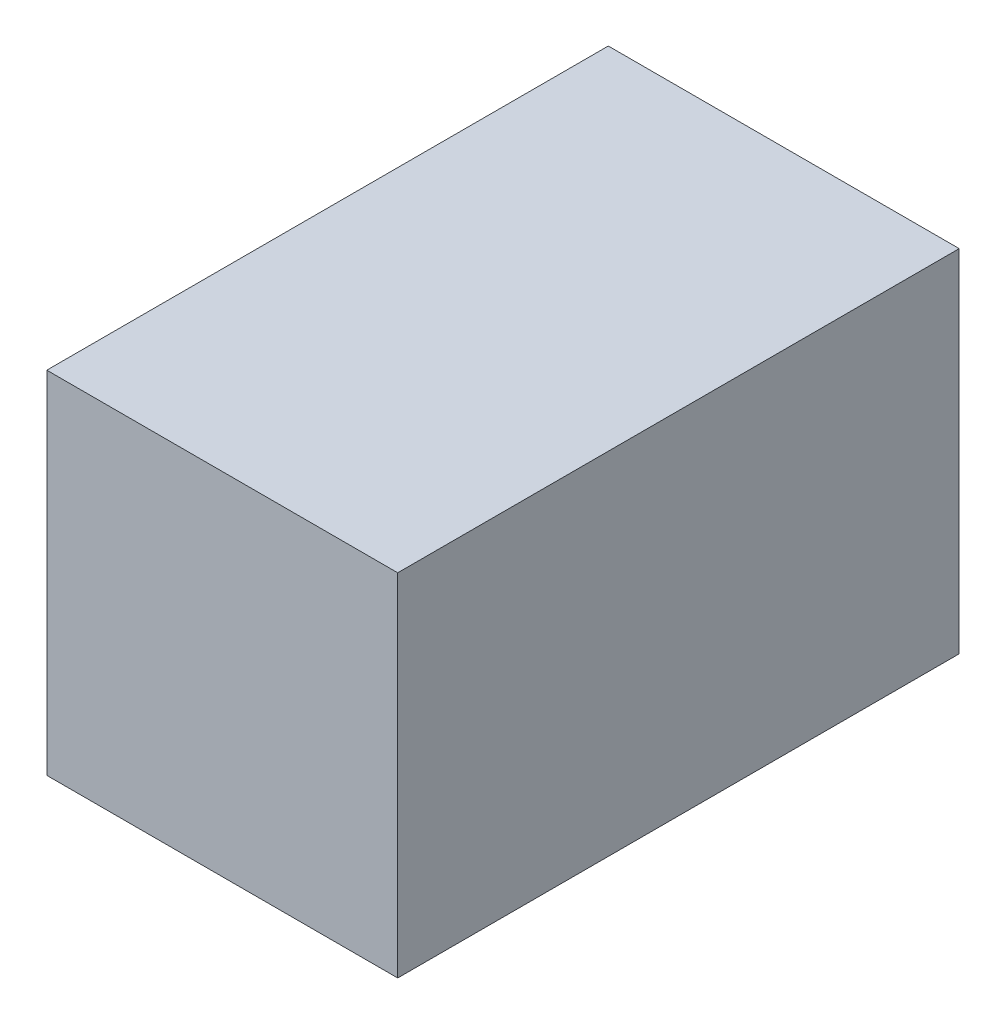
from build123d import *

# Parameters (mm, degrees)
SKETCH1_W           = 63.5
SKETCH1_H           = 101.6
BOSS_EXTRUDE1_DEPTH = 63.5


with BuildPart() as part:
    # Sketch1 → Boss-Extrude1 (new body)
    with BuildSketch(Plane(origin=(0, 0, 0), x_dir=(1, 0, 0), z_dir=(0, 1, 0))):
        Rectangle(SKETCH1_W, SKETCH1_H)
    extrude(amount=BOSS_EXTRUDE1_DEPTH)


solid = part.part
